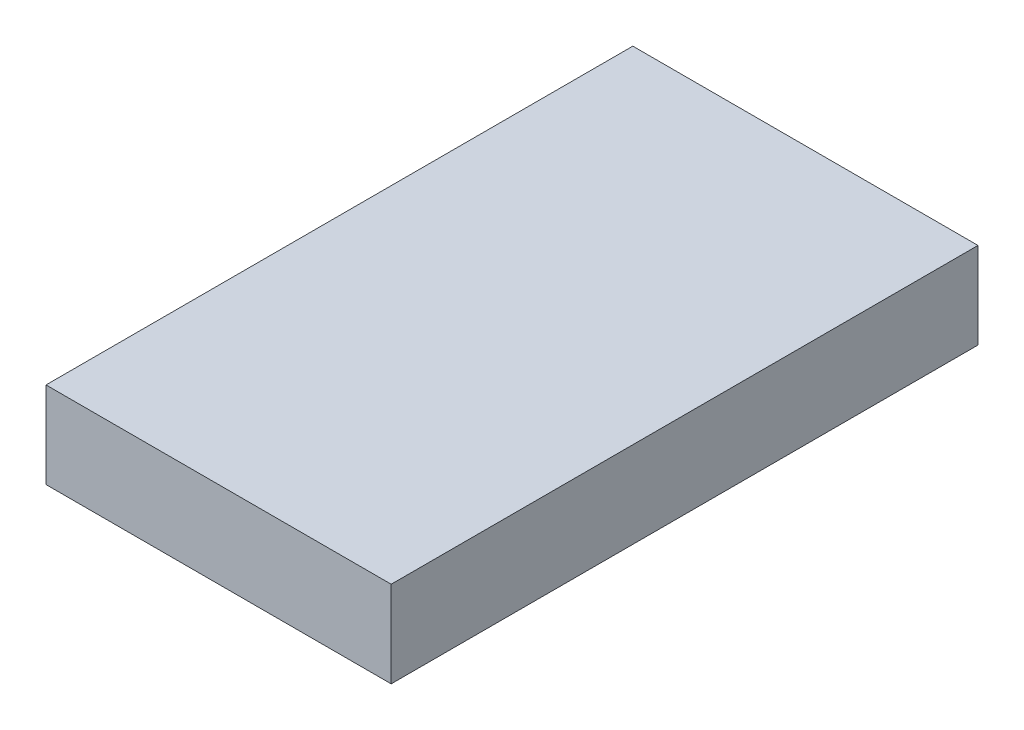
from build123d import *

# Parameters (mm, degrees)
SKETCH1_W           = 120
SKETCH1_H           = 204
BOSS_EXTRUDE1_DEPTH = 30


with BuildPart() as part:
    # Sketch1 → Boss-Extrude1 (new body)
    with BuildSketch(Plane(origin=(0, 0, 0), x_dir=(1, 0, 0), z_dir=(0, 1, 0))):
        Rectangle(SKETCH1_W, SKETCH1_H)
    extrude(amount=BOSS_EXTRUDE1_DEPTH)


solid = part.part
